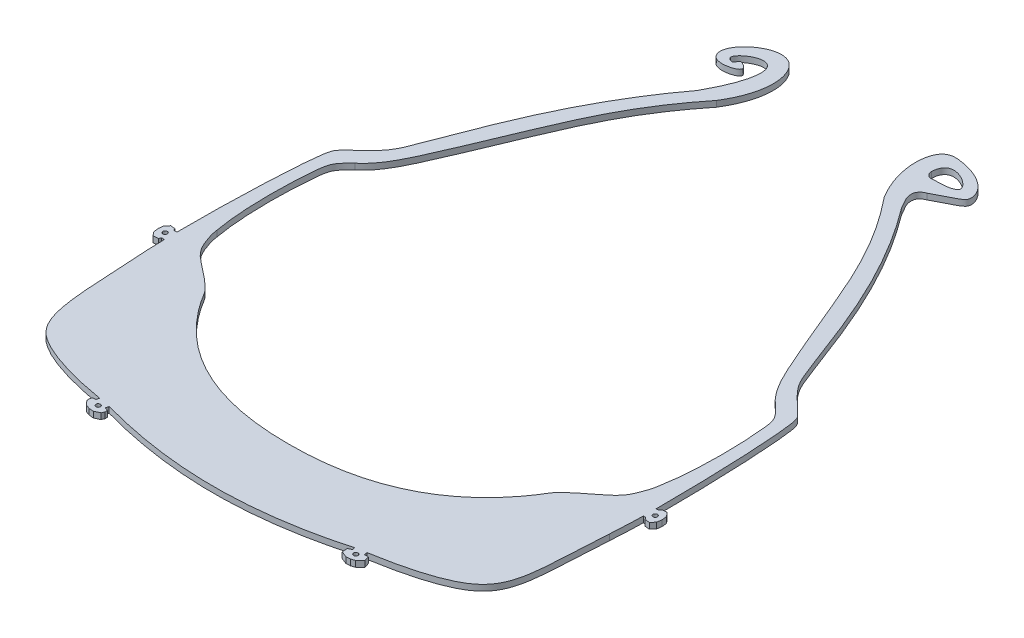
from build123d import *

# Parameters (mm, degrees)
SKETCH2_R           = 0.75
BOSS_EXTRUDE2_DEPTH = 2


with BuildPart() as part:
    # Sketch2 → Boss-Extrude2 (new body)
    with BuildSketch(Plane(origin=(0, 0, 0), x_dir=(1, 0, 0), z_dir=(0, 1, 0))):
        with BuildLine():
            Line((-16.94232243, 4635.297018365), (-18.534662591, 4633.795971308))
            Line((-18.534662591, 4633.795971308), (-19.887255597, 4633.340434244))
            Line((-19.887255597, 4633.340434244), (-21.312460887, 4633.264199495))
            Line((-21.312460887, 4633.264199495), (-23.346608072, 4634.07100473))
            Line((-23.346608072, 4634.07100473), (-23.480509856, 4635.86569876))
            Line((-23.480509856, 4635.86569876), (-22.26922003, 4636.472511323))
            Line((-22.26922003, 4636.472511323), (-22.498511996, 4637.355076027))
            add(Edge.make_bspline(
                [(-105.348248264, 4637.239361207), (-91.773973611, 4633.449581192), (-63.91646452, 4629.348089946), (-36.074978393, 4633.559092847), (-22.498511996, 4637.355076027)],
                knots=[0.018742307, 0.018742307, 0.018742307, 0.018742307, 0.500293183, 0.981944699, 0.981944699, 0.981944699, 0.981944699], degree=3))
            Line((-105.348248264, 4637.239361207), (-105.629701484, 4636.159523134))
            Line((-105.629701484, 4636.159523134), (-104.473549573, 4635.740406818))
            Line((-104.473549573, 4635.740406818), (-104.473549573, 4634.956711321))
            Line((-104.473549573, 4634.956711321), (-104.880493791, 4633.998010823))
            Line((-104.880493791, 4633.998010823), (-106.620311483, 4633.174408169))
            Line((-106.620311483, 4633.174408169), (-108.20431104, 4633.292684057))
            Line((-108.20431104, 4633.292684057), (-109.697513062, 4633.834340317))
            Line((-109.697513062, 4633.834340317), (-110.946606143, 4635.298940402))
            Line((-110.946606143, 4635.298940402), (-110.924641203, 4636.340202994))
            Line((-110.924641203, 4636.340202994), (-110.673720292, 4637.019084317))
            Line((-110.673720292, 4637.019084317), (-109.700510236, 4637.019084317))
            Line((-109.700510236, 4637.019084317), (-109.337236897, 4638.021190769))
            add(Edge.make_bspline(
                [(-109.337236897, 4638.021190769), (-119.14352525, 4639.685319313), (-132.602811475, 4643.251798031), (-144.259959312, 4654.289514228), (-143.359552227, 4671.437825607), (-144.749408582, 4689.48069966)],
                knots=[0.024855616, 0.024855616, 0.024855616, 0.024855616, 0.394717233, 0.49149328, 0.992616091, 0.992616091, 0.992616091, 0.992616091], degree=3))
            add(Edge.make_bspline(
                [(-144.749408582, 4689.48069966), (-144.833889745, 4691.307900212), (-144.896771823, 4693.342403801), (-144.93974364, 4695.519138342)],
                knots=[0.004734856, 0.004734856, 0.004734856, 0.004734856, 0.022822175, 0.022822175, 0.022822175, 0.022822175], degree=3))
            Line((-144.93974364, 4695.519138342), (-145.939352996, 4695.519138342))
            Line((-145.939352996, 4695.519138342), (-146.197672667, 4694.80522007))
            Line((-146.197672667, 4694.80522007), (-147.918372484, 4694.624725063))
            Line((-147.918372484, 4694.624725063), (-148.98298998, 4695.944509376))
            Line((-148.98298998, 4695.944509376), (-149.222790895, 4697.597182293))
            Line((-149.222790895, 4697.597182293), (-149.027988208, 4699.255761252))
            Line((-149.027988208, 4699.255761252), (-147.918372484, 4700.606196913))
            Line((-147.918372484, 4700.606196913), (-146.274658466, 4700.470317954))
            Line((-146.274658466, 4700.470317954), (-146.077436972, 4699.790846236))
            Line((-146.077436972, 4699.790846236), (-144.997793977, 4699.790846236))
            add(Edge.make_bspline(
                [(-144.997793977, 4699.790846236), (-145.140739705, 4717.900779), (-143.980499513, 4747.781602798), (-140.945925182, 4752.343329702), (-133.518546426, 4758.095548291), (-125.834467772, 4776.247277702), (-117.076856476, 4804.544180166), (-98.462694945, 4829.308158932)],
                knots=[0.034255764, 0.034255764, 0.034255764, 0.034255764, 0.174203465, 0.204984692, 0.326836548, 0.407861227, 1, 1, 1, 1], degree=3))
            add(Edge.make_bspline(
                [(-98.462694945, 4829.308158932), (-93.338195312, 4838.574633039), (-90.195516318, 4855.063159321), (-104.870066172, 4845.568494242), (-99.312588758, 4842.31908912), (-101.029716126, 4847.036920255), (-95.531835724, 4842.382392631), (-104.17457082, 4840.110977299), (-108.484196771, 4847.903909117), (-89.394263588, 4862.544739312), (-85.254664303, 4840.959775456), (-92.294467324, 4829.654236917)],
                knots=[0, 0, 0, 0, 0.089848065, 0.265684805, 0.309990571, 0.508137378, 0.544429531, 0.636619953, 0.668771421, 0.854420413, 1, 1, 1, 1], degree=3))
            add(Edge.make_bspline(
                [(-135.032740768, 4750.111001922), (-130.492777431, 4753.915516125), (-113.368729467, 4791.023782379), (-108.982672337, 4808.826517659), (-92.294467324, 4829.654236917)],
                knots=[0, 0, 0, 0, 0.147117654, 0.925748444, 0.925748444, 0.925748444, 0.925748444], degree=3))
            add(Edge.make_bspline(
                [(-138.776603849, 4707.061813065), (-140.372417965, 4715.665959829), (-140.797792532, 4730.905308146), (-139.055824108, 4746.24867545), (-136.530200286, 4748.70910668), (-135.032740768, 4750.111001922)],
                knots=[0, 0, 0, 0, 0.797699661, 0.897699661, 1, 1, 1, 1], degree=3))
            add(Edge.make_bspline(
                [(-122.553716851, 4686.669702846), (-124.458572981, 4689.514746254), (-133.378914312, 4695.631638467), (-134.862520268, 4697.627016687), (-136.765281392, 4699.957235784), (-138.495666225, 4704.644766972), (-138.776603849, 4707.061813065)],
                knots=[0, 0, 0, 0, 0.517384858, 0.711983816, 0.762677817, 1, 1, 1, 1], degree=3))
            add(Edge.make_bspline(
                [(-63.92338013, 4656.572608608), (-104.524638736, 4656.452117341), (-122.553716851, 4686.669702846)],
                knots=[0, 0, 0, 1, 1, 1], degree=2))
            add(Edge.make_bspline(
                [(-63.92338013, 4656.572608608), (-23.322121525, 4656.452117341), (-5.29304341, 4686.669702846)],
                knots=[0, 0, 0, 1, 1, 1], degree=2))
            add(Edge.make_bspline(
                [(-5.29304341, 4686.669702846), (-3.38818728, 4689.514746254), (5.532154051, 4695.631638467), (7.015760007, 4697.627016687), (8.918521131, 4699.957235784), (10.648905964, 4704.644766972), (10.929843589, 4707.061813065)],
                knots=[0, 0, 0, 0, 0.517384858, 0.711983816, 0.762677817, 1, 1, 1, 1], degree=3))
            add(Edge.make_bspline(
                [(10.929843589, 4707.061813065), (12.525657705, 4715.665959829), (12.951032272, 4730.905308146), (11.209063847, 4746.24867545), (8.683440025, 4748.70910668), (7.185980508, 4750.111001922)],
                knots=[0, 0, 0, 0, 0.797699661, 0.897699661, 1, 1, 1, 1], degree=3))
            add(Edge.make_bspline(
                [(7.185980508, 4750.111001922), (2.64601717, 4753.915516125), (-14.478030794, 4791.023782379), (-18.864087923, 4808.826517659), (-35.552292937, 4829.654236917)],
                knots=[0, 0, 0, 0, 0.147117654, 0.925748444, 0.925748444, 0.925748444, 0.925748444], degree=3))
            add(Edge.make_bspline(
                [(-29.577159118, 4838.067403545), (-27.545051952, 4839.127132506), (-21.379492189, 4842.022083013), (-19.627523599, 4845.365560863), (-23.645596823, 4852.386092575), (-41.376537478, 4854.028844833), (-41.888115655, 4839.829221602), (-35.552292937, 4829.654236917)],
                knots=[0.329045507, 0.329045507, 0.329045507, 0.329045507, 0.434681958, 0.485510559, 0.7982403, 0.853598366, 1, 1, 1, 1], degree=3))
            add(Edge.make_bspline(
                [(-29.384065315, 4829.308158932), (-30.279828858, 4830.927940426), (-32.337483277, 4833.601150674), (-31.918610801, 4837.198474175), (-29.577159118, 4838.067403545)],
                knots=[0, 0, 0, 0, 0.008448935, 0.016897871, 0.016897871, 0.016897871, 0.016897871], degree=3))
            add(Edge.make_bspline(
                [(17.151033717, 4699.790846236), (17.186998591, 4718.753185432), (15.94634825, 4748.148860321), (12.996151343, 4752.209564814), (5.590245105, 4758.14453206), (-2.080870076, 4776.039451645), (-10.769903785, 4804.544180166), (-29.384065315, 4829.308158932)],
                knots=[0.044450265, 0.044450265, 0.044450265, 0.044450265, 0.175222915, 0.204984692, 0.326836548, 0.407861227, 1, 1, 1, 1], degree=3))
            Line((17.151033717, 4699.790846236), (17.927254585, 4699.790846236))
            Line((17.927254585, 4699.790846236), (18.427898205, 4700.470317954))
            Line((18.427898205, 4700.470317954), (20.071612224, 4700.606196913))
            Line((20.071612224, 4700.606196913), (21.181227948, 4699.255761252))
            Line((21.181227948, 4699.255761252), (21.376030634, 4697.597182293))
            Line((21.376030634, 4697.597182293), (21.136229719, 4695.944509376))
            Line((21.136229719, 4695.944509376), (19.990327064, 4694.624725063))
            Line((19.990327064, 4694.624725063), (18.350912407, 4694.80522007))
            Line((18.350912407, 4694.80522007), (17.926998071, 4695.519138342))
            Line((17.926998071, 4695.519138342), (17.092983379, 4695.519138342))
            add(Edge.make_bspline(
                [(16.61721801, 4684.514714632), (16.759333405, 4687.588466409), (17.055168032, 4691.324791696), (17.092983379, 4695.519138342)],
                knots=[0.004734857, 0.004734857, 0.004734857, 0.004734857, 0.035161677, 0.035161677, 0.035161677, 0.035161677], degree=3))
            add(Edge.make_bspline(
                [(-18.943384636, 4638.035656948), (-9.024791136, 4639.685871765), (4.646728482, 4643.060373116), (16.372015333, 4654.394416396), (15.252352932, 4666.334603474), (16.61721801, 4684.514714632)],
                knots=[0.018902136, 0.018902136, 0.018902136, 0.018902136, 0.394121885, 0.490994555, 0.987628845, 0.987628845, 0.987628845, 0.987628845], degree=3))
            Line((-18.943384636, 4638.035656948), (-18.723139757, 4637.014274136))
            Line((-18.723139757, 4637.014274136), (-17.480735808, 4637.014274136))
            Line((-17.480735808, 4637.014274136), (-16.94232243, 4635.297018365))
        make_face()
        with Locations((-20.331640643, 4635.661753265)):
            Circle(SKETCH2_R, mode=Mode.SUBTRACT)
        with Locations((-107.515119617, 4635.661753265)):
            Circle(SKETCH2_R, mode=Mode.SUBTRACT)
        with Locations((18.97346222, 4697.629831976)):
            Circle(SKETCH2_R, mode=Mode.SUBTRACT)
        with Locations((-146.82022248, 4697.629831976)):
            Circle(SKETCH2_R, mode=Mode.SUBTRACT)
        with BuildLine():
            Line((-32.298353483, 4843.110786916), (-32.973361471, 4843.074499622))
            ThreePointArc((-32.973361471, 4843.074499622), (-34.462427064, 4843.625623485), (-35.080655121, 4845.088103544))
            add(Edge.make_bspline(
                [(-35.080655121, 4845.088103544), (-35.07522376, 4845.746921826), (-34.054641359, 4853.099908746), (-22.802907261, 4845.875599853), (-27.213531859, 4843.060134174), (-30.503691524, 4843.207264923), (-32.298353483, 4843.110786916)],
                knots=[0.039445136, 0.039445136, 0.039445136, 0.039445136, 0.047752147, 0.136145501, 0.152448067, 0.210777803, 0.210777803, 0.210777803, 0.210777803], degree=3))
        make_face(mode=Mode.SUBTRACT)
    extrude(amount=BOSS_EXTRUDE2_DEPTH)


solid = part.part
